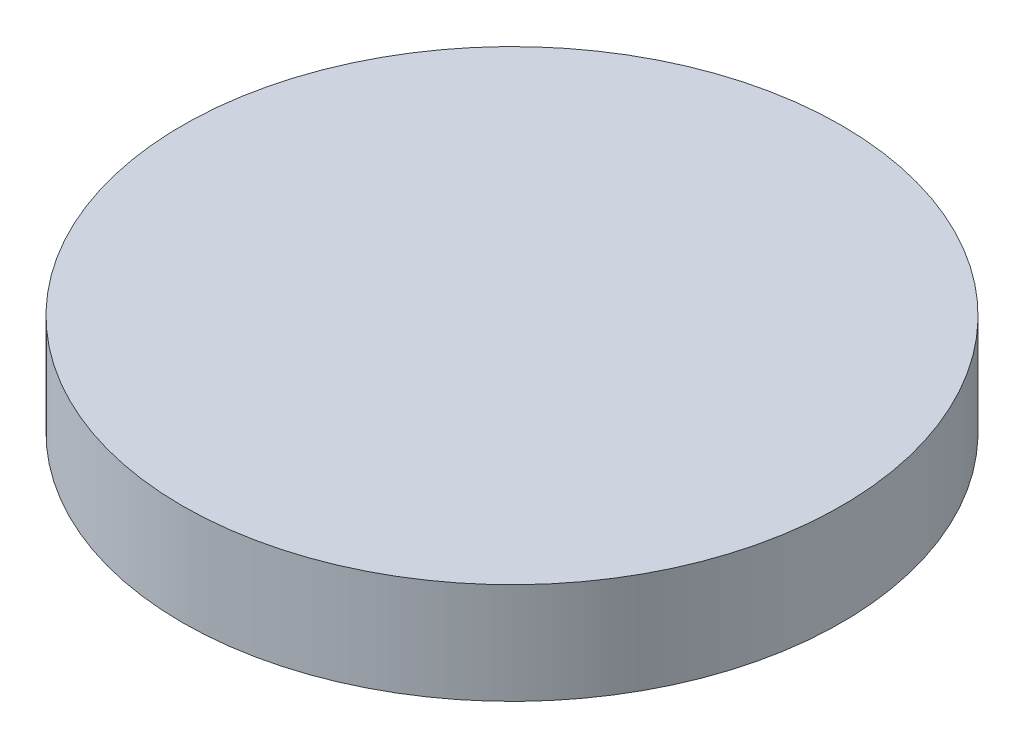
from build123d import *

# Parameters (mm, degrees)
SKETCH1_R           = 3.26057443
BOSS_EXTRUDE1_DEPTH = 1


with BuildPart() as part:
    # Sketch1 → Boss-Extrude1 (new body)
    with BuildSketch(Plane(origin=(0, 0, 0), x_dir=(1, 0, 0), z_dir=(0, 1, 0))):
        Circle(SKETCH1_R)
    extrude(amount=BOSS_EXTRUDE1_DEPTH)


solid = part.part
